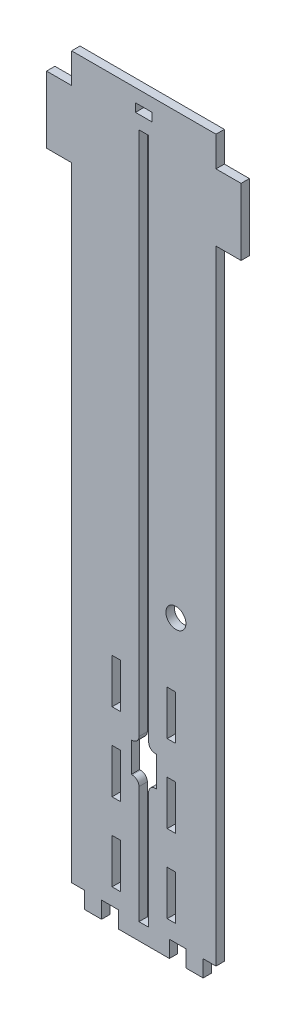
from build123d import *

# Parameters (mm, degrees)
SKETCH1_W           = 54.864
SKETCH1_H           = 280.162
SKETCH1_W_2         = 3.683
SKETCH1_H_2         = 260.604
BOSS_EXTRUDE1_DEPTH = 3.175
SKETCH2_W           = 3.175
SKETCH2_H           = 101.6
BOSS_EXTRUDE2_DEPTH = 3.175
SKETCH3_W           = 225.425
SKETCH3_H           = 6.35
BOSS_EXTRUDE3_DEPTH = 51.689
SKETCH7_W           = 327.022738736
SKETCH7_H           = 279.435650021
CUT_EXTRUDE1_DEPTH  = 55.864
SKETCH4_W           = 6.35
SKETCH4_H           = 3.175
SKETCH4_W_2         = 4.8895
SKETCH4_H_2         = 12.7
CUT_EXTRUDE2_DEPTH  = 6.35
SKETCH8_W           = 9.525
SKETCH8_H           = 25.4
BOSS_EXTRUDE4_DEPTH = 3.175
SKETCH9_W           = 3.175
SKETCH9_H           = 16.933333333
SKETCH9_H_2         = 16.933333334
CUT_EXTRUDE4_DEPTH  = 4.175
SKETCH10_W          = 6.35
SKETCH10_H          = 3.175
CUT_EXTRUDE5_DEPTH  = 4.175
SKETCH13_W          = 9.525
SKETCH13_H          = 11.43
CUT_EXTRUDE7_DEPTH  = 4.175
SKETCH14_R          = 3.81
CUT_EXTRUDE8_DEPTH  = 4.175
FILLET1_R           = 2.54


with BuildPart() as part:
    # Sketch1 → Boss-Extrude1 (new body)
    with BuildSketch(Plane.XY):
        with Locations((0, 3.429)):
            Rectangle(SKETCH1_W, SKETCH1_H)
        Rectangle(SKETCH1_W_2, SKETCH1_H_2, mode=Mode.SUBTRACT)
    extrude(amount=BOSS_EXTRUDE1_DEPTH)

    # Sketch2 → Boss-Extrude2 (add)
    with BuildSketch(Plane(origin=(27.432, 0, 0), x_dir=(0, 0, -1), z_dir=(1, 0, 0))):
        Polygon((225.425, -47.752), (225.425, -35.052), (0, -35.052), (0, -136.652), (225.425, -136.652), (225.425, -123.952), (228.6, -123.952), (228.6, -107.018666667), (225.425, -107.018666667), (225.425, -94.318666667), (228.6, -94.318666667), (228.6, -77.385333333), (225.425, -77.385333333), (225.425, -64.685333333), (228.6, -64.685333333), (228.6, -47.752), align=None)
        with BuildLine():
            ThreePointArc((11.4, -103.892), (9.9, -105.392), (8.4, -103.892))
            Line((8.4, -103.892), (8.4, -98.812))
            ThreePointArc((8.4, -98.812), (9.9, -97.312), (11.4, -98.812))
            Line((11.4, -98.812), (11.4, -103.892))
        make_face(mode=Mode.SUBTRACT)
        with BuildLine():
            Line((42.4, -98.812), (42.4, -103.892))
            ThreePointArc((42.4, -103.892), (40.9, -105.392), (39.4, -103.892))
            Line((39.4, -103.892), (39.4, -98.812))
            ThreePointArc((39.4, -98.812), (40.9, -97.312), (42.4, -98.812))
        make_face(mode=Mode.SUBTRACT)
        with BuildLine():
            ThreePointArc((36.4, -88.392), (25.4, -99.392), (14.4, -88.392))
            Line((14.4, -88.392), (14.4, -83.312))
            ThreePointArc((14.4, -83.312), (25.4, -72.312), (36.4, -83.312))
            Line((36.4, -83.312), (36.4, -88.392))
        make_face(mode=Mode.SUBTRACT)
        with BuildLine():
            ThreePointArc((11.4, -72.892), (9.9, -74.392), (8.4, -72.892))
            Line((8.4, -72.892), (8.4, -67.812))
            ThreePointArc((8.4, -67.812), (9.9, -66.312), (11.4, -67.812))
            Line((11.4, -67.812), (11.4, -72.892))
        make_face(mode=Mode.SUBTRACT)
        with BuildLine():
            ThreePointArc((42.4, -72.892), (40.9, -74.392), (39.4, -72.892))
            Line((39.4, -72.892), (39.4, -67.812))
            ThreePointArc((39.4, -67.812), (40.9, -66.312), (42.4, -67.812))
            Line((42.4, -67.812), (42.4, -72.892))
        make_face(mode=Mode.SUBTRACT)
        with Locations((-1.5875, -85.852)):
            Rectangle(SKETCH2_W, SKETCH2_H)
    extrude(amount=-BOSS_EXTRUDE2_DEPTH)

    # Sketch3 → Boss-Extrude3 (add)
    with BuildSketch(Plane.ZY.offset(-24.257)):
        with Locations((-112.7125, -133.477)):
            Rectangle(SKETCH3_W, SKETCH3_H)
    extrude(amount=BOSS_EXTRUDE3_DEPTH)

    # Sketch7 → Cut-Extrude1 (cut, through all)
    with BuildSketch(Plane(origin=(27.432, 0, 0), x_dir=(0, 0, -1), z_dir=(1, 0, 0))):
        with Locations((163.511369368, -148.348068682)):
            Rectangle(SKETCH7_W, SKETCH7_H)
    extrude(amount=-CUT_EXTRUDE1_DEPTH, mode=Mode.SUBTRACT)

    # Sketch4 → Cut-Extrude2 (cut)
    with BuildSketch(Plane.XZ.offset(136.652)):
        with Locations((-12.8905, 1.5875)):
            Rectangle(SKETCH4_W, SKETCH4_H)
        with Locations((24.98725, 1.5875)):
            Rectangle(SKETCH4_W_2, SKETCH4_H)
        with Locations((-24.98725, 1.5875)):
            Rectangle(SKETCH4_W_2, SKETCH4_H)
        with Locations((12.8905, 1.5875)):
            Rectangle(SKETCH4_W, SKETCH4_H)
        with Locations((24.98725, -138.1125)):
            Rectangle(SKETCH4_W_2, SKETCH4_H_2)
        with Locations((24.98725, -57.15)):
            Rectangle(SKETCH4_W_2, SKETCH4_H_2)
        with Locations((24.98725, -165.1)):
            Rectangle(SKETCH4_W_2, SKETCH4_H_2)
    extrude(amount=-CUT_EXTRUDE2_DEPTH, mode=Mode.SUBTRACT)

    # Sketch8 → Boss-Extrude4 (add)
    with BuildSketch(Plane.XY.offset(3.175)):
        with Locations((-32.1945, 119.38)):
            Rectangle(SKETCH8_W, SKETCH8_H)
        with Locations((32.1945, 119.38)):
            Rectangle(SKETCH8_W, SKETCH8_H)
    extrude(amount=-BOSS_EXTRUDE4_DEPTH)

    # Sketch9 → Cut-Extrude4 (cut, through all)
    with BuildSketch(Plane.XY.offset(3.175)):
        with Locations((-10.4775, -56.218666666)):
            Rectangle(SKETCH9_W, SKETCH9_H)
        with Locations((-10.4775, -85.852)):
            Rectangle(SKETCH9_W, SKETCH9_H_2)
        with Locations((-10.4775, -115.485333334)):
            Rectangle(SKETCH9_W, SKETCH9_H)
        with Locations((10.4775, -56.218666666)):
            Rectangle(SKETCH9_W, SKETCH9_H)
        with Locations((10.4775, -85.852)):
            Rectangle(SKETCH9_W, SKETCH9_H_2)
        with Locations((10.4775, -115.485333334)):
            Rectangle(SKETCH9_W, SKETCH9_H)
    extrude(amount=-CUT_EXTRUDE4_DEPTH, mode=Mode.SUBTRACT)

    # Sketch10 → Cut-Extrude5 (cut, through all)
    with BuildSketch(Plane.XY.offset(3.175)):
        with Locations((0, 136.9695)):
            Rectangle(SKETCH10_W, SKETCH10_H)
    extrude(amount=-CUT_EXTRUDE5_DEPTH, mode=Mode.SUBTRACT)

    # Sketch13 → Cut-Extrude7 (cut, through all)
    with BuildSketch(Plane.XY.offset(3.175)):
        with Locations((0, -77.597)):
            Rectangle(SKETCH13_W, SKETCH13_H)
    extrude(amount=-CUT_EXTRUDE7_DEPTH, mode=Mode.SUBTRACT)

    # Sketch14 → Cut-Extrude8 (cut, through all)
    with BuildSketch(Plane.XY.offset(3.175)):
        with Locations((12.192, -23.3172)):
            Circle(SKETCH14_R)
    extrude(amount=-CUT_EXTRUDE8_DEPTH, mode=Mode.SUBTRACT)

    # Fillet1
    fillet1_edges = [part.edges().sort_by_distance(p)[0] for p in [
        (-1.8415, -83.312, 1.5875),
        (-1.8415, -71.882, 1.5875),
        (1.8415, -71.882, 1.5875),
        (1.8415, -83.312, 1.5875),
    ]]
    fillet(fillet1_edges, radius=FILLET1_R)


solid = part.part
